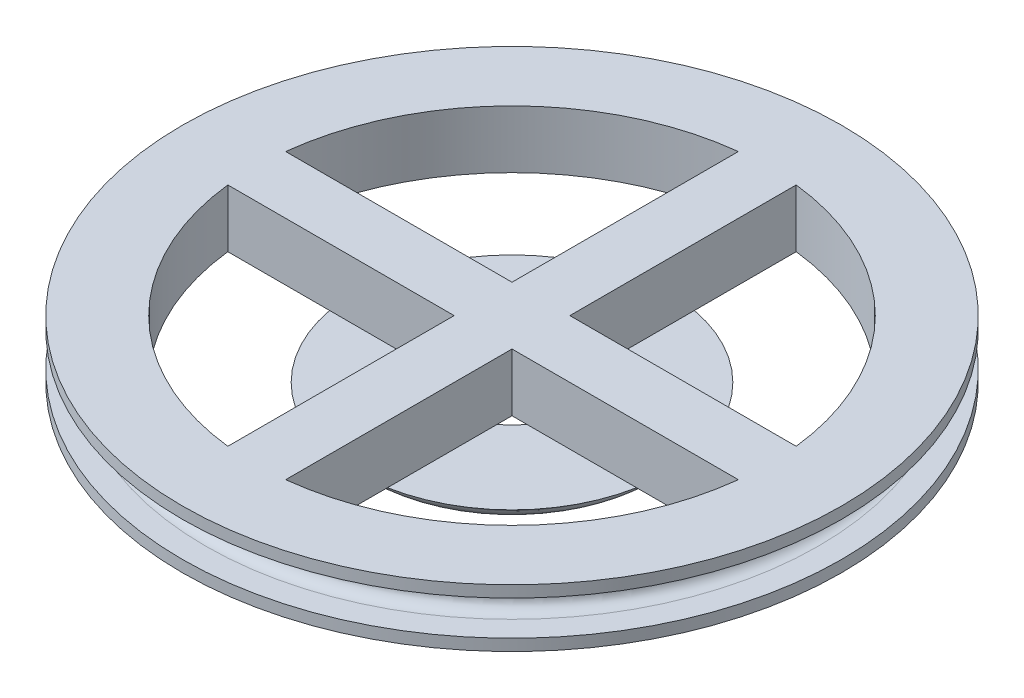
from build123d import *

# Parameters (mm, degrees)
SKETCH1_R            = 25
BOSS_EXTRUDE2_DEPTH  = 3
SKETCH3_R            = 57
BOSS_EXTRUDE10_DEPTH = 2
SKETCH8_R            = 51
SKETCH8_R_2          = 45
BOSS_EXTRUDE11_DEPTH = 6
SKETCH9_R            = 10
BOSS_EXTRUDE12_DEPTH = 6
SKETCH10_R           = 57
BOSS_EXTRUDE13_DEPTH = 2
FILLET1_R            = 2
FILLET2_R            = 2
FILLET3_R            = 2
FILLET4_R            = 2
SKETCH11_R           = 50
BOSS_EXTRUDE14_DEPTH = 10
CUT_EXTRUDE3_DEPTH   = 10


with BuildPart() as part:
    # Sketch1 → Boss-Extrude2 (new body)
    with BuildSketch(Plane(origin=(0, 0, 0), x_dir=(1, 0, 0), z_dir=(0, 1, 0))):
        Circle(SKETCH1_R)
        with BuildLine():
            Line((20, -3.5), (7.537849637, -5))
            ThreePointArc((7.537849637, -5), (6.396060395, -6.396060395), (5, -7.537849637))
            Line((5, -7.537849637), (3.5, -20))
            Line((3.5, -20), (-3.5, -20))
            Line((-3.5, -20), (-5, -7.537849637))
            ThreePointArc((-5, -7.537849637), (-6.396060395, -6.396060395), (-7.537849637, -5))
            Line((-7.537849637, -5), (-20, -3.5))
            Line((-20, -3.5), (-20, 3.5))
            Line((-20, 3.5), (-7.537849637, 5))
            ThreePointArc((-7.537849637, 5), (-6.396060395, 6.396060395), (-5, 7.537849637))
            Line((-5, 7.537849637), (-3.5, 20))
            Line((-3.5, 20), (3.5, 20))
            Line((3.5, 20), (5, 7.537849637))
            ThreePointArc((5, 7.537849637), (6.396060395, 6.396060395), (7.537849637, 5))
            Line((7.537849637, 5), (20, 3.5))
            Line((20, 3.5), (20, -3.5))
        make_face(mode=Mode.SUBTRACT)
    extrude(amount=BOSS_EXTRUDE2_DEPTH)

    # Sketch3 → Boss-Extrude10 (add)
    with BuildSketch(Plane(origin=(0, 3, 0), x_dir=(1, 0, 0), z_dir=(0, 1, 0))):
        Circle(SKETCH3_R)
    extrude(amount=BOSS_EXTRUDE10_DEPTH)

    # Sketch8 → Boss-Extrude11 (add)
    with BuildSketch(Plane(origin=(0, 5, 0), x_dir=(1, 0, 0), z_dir=(0, 1, 0))):
        Circle(SKETCH8_R)
        Circle(SKETCH8_R_2, mode=Mode.SUBTRACT)
    extrude(amount=BOSS_EXTRUDE11_DEPTH)

    # Sketch9 → Boss-Extrude12 (add)
    with BuildSketch(Plane(origin=(0, 5, 0), x_dir=(1, 0, 0), z_dir=(0, 1, 0))):
        Circle(SKETCH9_R)
    extrude(amount=BOSS_EXTRUDE12_DEPTH)

    # Sketch10 → Boss-Extrude13 (add)
    with BuildSketch(Plane(origin=(0, 11, 0), x_dir=(1, 0, 0), z_dir=(0, 1, 0))):
        Circle(SKETCH10_R)
    extrude(amount=BOSS_EXTRUDE13_DEPTH)

    # Fillet1
    fillet1_edges = [part.edges().sort_by_distance(p)[0] for p in [
        (-51, 11, 0),
    ]]
    fillet(fillet1_edges, radius=FILLET1_R)

    # Fillet2
    fillet2_edges = [part.edges().sort_by_distance(p)[0] for p in [
        (-51, 5, 0),
    ]]
    fillet(fillet2_edges, radius=FILLET2_R)

    # Fillet3
    fillet3_edges = [part.edges().sort_by_distance(p)[0] for p in [
        (-25, 3, 0),
    ]]
    fillet(fillet3_edges, radius=FILLET3_R)

    # Fillet4
    fillet4_edges = [part.edges().sort_by_distance(p)[0] for p in [
        (-25, 0, 0),
    ]]
    fillet(fillet4_edges, radius=FILLET4_R)

    # Sketch11 → Boss-Extrude14 (add)
    with BuildSketch(Plane(origin=(0, 13, 0), x_dir=(1, 0, 0), z_dir=(0, 1, 0))):
        Circle(SKETCH11_R)
    extrude(amount=-BOSS_EXTRUDE14_DEPTH)

    # Sketch12 → Cut-Extrude3 (cut)
    with BuildSketch(Plane(origin=(0, 13, 0), x_dir=(1, 0, 0), z_dir=(0, 1, 0))):
        with BuildLine():
            Line((44.129475009, -5), (5, -5))
            Line((5, -5), (5, -44.129475009))
            ThreePointArc((5, -44.129475009), (31.403905526, -31.403905526), (44.129475009, -5))
        make_face()
        with BuildLine():
            Line((5, 5), (44.129475009, 5))
            ThreePointArc((44.129475009, 5), (31.403905526, 31.403905526), (5, 44.129475009))
            Line((5, 44.129475009), (5, 5))
        make_face()
        with BuildLine():
            Line((-44.129475009, 5), (-5, 5))
            Line((-5, 5), (-5, 44.129475009))
            ThreePointArc((-5, 44.129475009), (-31.403905526, 31.403905526), (-44.129475009, 5))
        make_face()
        with BuildLine():
            Line((-5, -44.129475009), (-5, -5))
            Line((-5, -5), (-44.129475009, -5))
            ThreePointArc((-44.129475009, -5), (-31.403905526, -31.403905526), (-5, -44.129475009))
        make_face()
    extrude(amount=-CUT_EXTRUDE3_DEPTH, mode=Mode.SUBTRACT)


solid = part.part
